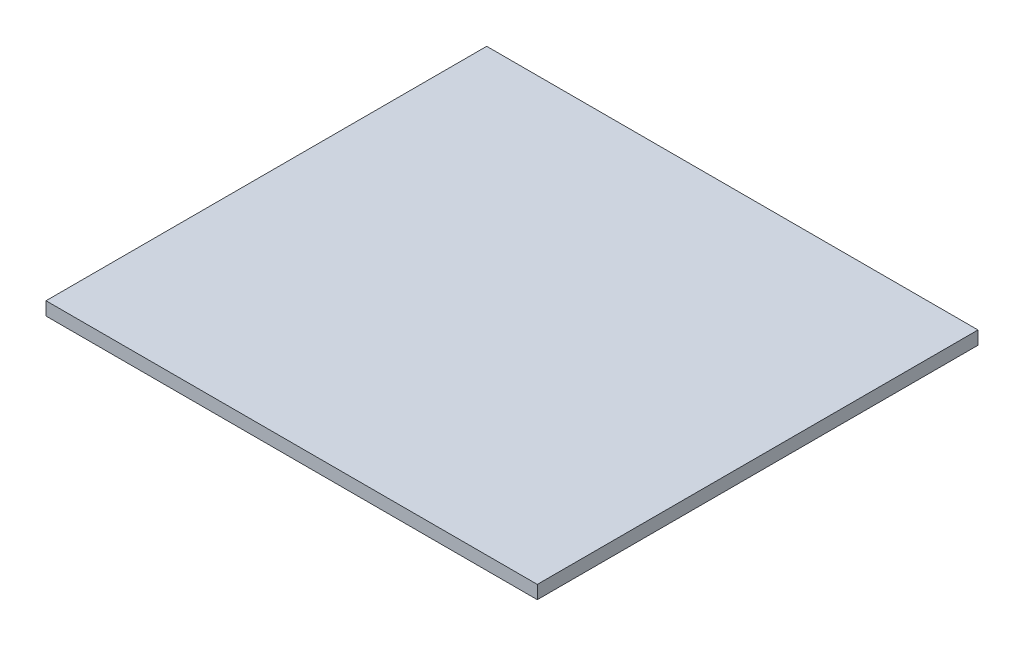
from build123d import *

# Parameters (mm, degrees)
SKETCH1_W           = 470
SKETCH1_H           = 421.6
BOSS_EXTRUDE1_DEPTH = 12.7


with BuildPart() as part:
    # Sketch1 → Boss-Extrude1 (new body)
    with BuildSketch(Plane(origin=(0, 0, 0), x_dir=(1, 0, 0), z_dir=(0, 1, 0))):
        Rectangle(SKETCH1_W, SKETCH1_H)
    extrude(amount=BOSS_EXTRUDE1_DEPTH)


solid = part.part
